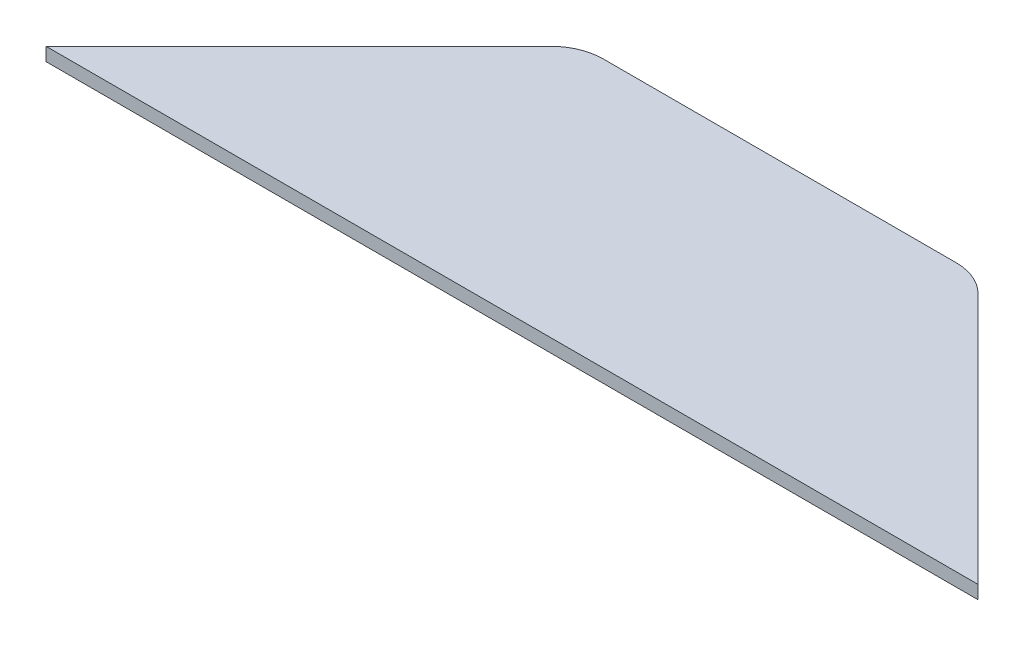
from build123d import *

# Parameters (mm, degrees)
EXTRUDE1_DEPTH = 1.6002


with BuildPart() as part:
    # Sketch1 → Extrude1 (new body)
    with BuildSketch(Plane(origin=(0, 0, 0), x_dir=(1, 0, 0), z_dir=(0, 1, 0))):
        with BuildLine():
            Line((21.182243879, 0), (-21.182243879, 0))
            ThreePointArc((-21.182243879, 0), (-23.612283674, -0.483364969), (-25.672371939, -1.859871939))
            Line((-25.672371939, -1.859871939), (-55.9435, -32.131))
            Line((-55.9435, -32.131), (55.9435, -32.131))
            Line((55.9435, -32.131), (25.672371939, -1.859871939))
            ThreePointArc((25.672371939, -1.859871939), (23.612283674, -0.483364969), (21.182243879, 0))
        make_face()
    extrude(amount=EXTRUDE1_DEPTH)


solid = part.part
